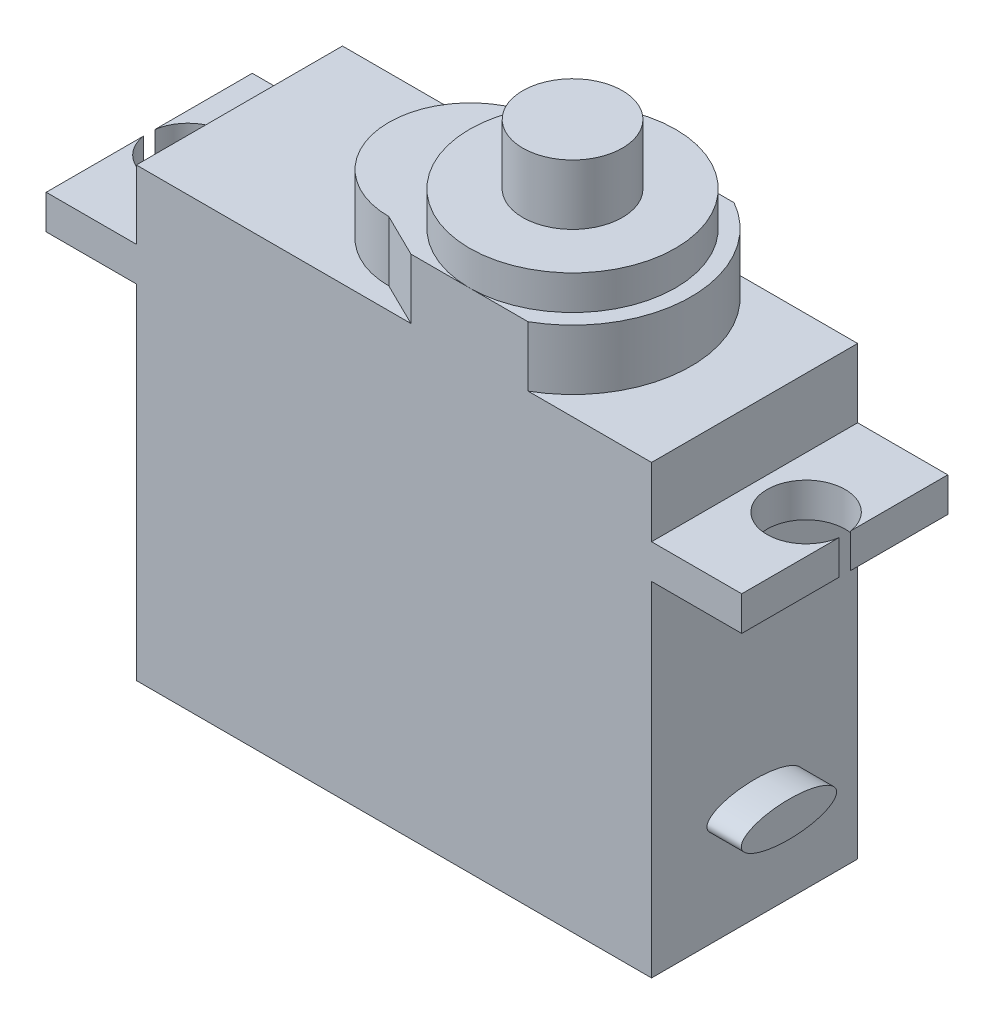
from build123d import *

# Parameters (mm, degrees)
BOSS_EXTRUDE1_DEPTH = 12
SKETCH2_RX          = 2.776601092
SKETCH2_RY          = 1.017784095
BOSS_EXTRUDE2_DEPTH = 2
SKETCH3_R           = 2.275
CUT_EXTRUDE3_DEPTH  = 2
SKETCH5_R           = 2.9
BOSS_EXTRUDE3_DEPTH = 3.5
CUT_EXTRUDE4_DEPTH  = 5.5
CUT_EXTRUDE5_DEPTH  = 2
CUT_EXTRUDE6_DEPTH  = 3.5


with BuildPart() as part:
    # Sketch1 → Boss-Extrude1 (new body)
    with BuildSketch(Plane.XY):
        Polygon((0, 22), (0, 26), (8.7, 26), (8.7, 31.5), (26.3, 31.5), (26.3, 26), (30, 26), (30, 22), (35.25, 22), (35.25, 20), (30, 20), (30, 0), (0, 0), (0, 20), (-5.25, 20), (-5.25, 22), align=None)
    extrude(amount=BOSS_EXTRUDE1_DEPTH)

    # Sketch2 → Boss-Extrude2 (add)
    with BuildSketch(Plane(origin=(30, 0, 0), x_dir=(0, 0, -1), z_dir=(1, 0, 0))):
        with Locations((-6, 6)):
            Ellipse(SKETCH2_RX, SKETCH2_RY)
    extrude(amount=BOSS_EXTRUDE2_DEPTH)

    # Sketch3 → Cut-Extrude3 (cut)
    with BuildSketch(Plane(origin=(0, 22, 0), x_dir=(1, 0, 0), z_dir=(0, 1, 0))):
        with Locations((-3, -6)):
            Circle(SKETCH3_R)
        with Locations((33, -6)):
            Circle(SKETCH3_R)
    extrude(amount=-CUT_EXTRUDE3_DEPTH, mode=Mode.SUBTRACT)

    # Sketch5 → Boss-Extrude3 (add)
    with BuildSketch(Plane(origin=(0, 31.5, 0), x_dir=(1, 0, 0), z_dir=(0, 1, 0))):
        with Locations((19.4, -6)):
            Circle(SKETCH5_R)
    extrude(amount=BOSS_EXTRUDE3_DEPTH)

    # Sketch5_3 → Cut-Extrude4 (cut)
    with BuildSketch(Plane(origin=(0, 31.5, 0), x_dir=(1, 0, 0), z_dir=(0, 1, 0))):
        with BuildLine():
            Line((26.3, 0), (22.807345007, 0))
            ThreePointArc((22.807345007, 0), (25.363249137, -2.528738021), (26.3, -6))
            Line((26.3, -6), (26.3, 0))
        make_face()
        with BuildLine():
            Line((26.3, -12), (26.3, -6))
            ThreePointArc((26.3, -6), (25.363249137, -9.471261979), (22.807345007, -12))
            Line((22.807345007, -12), (26.3, -12))
        make_face()
    extrude(amount=-CUT_EXTRUDE4_DEPTH, mode=Mode.SUBTRACT)

    # Sketch7 → Cut-Extrude5 (cut)
    with BuildSketch(Plane(origin=(0, 31.5, 0), x_dir=(1, 0, 0), z_dir=(0, 1, 0))):
        with BuildLine():
            ThreePointArc((22.807345007, -12), (26.3, -6), (22.807345007, 0))
            Line((22.807345007, 0), (19.4, 0))
            ThreePointArc((19.4, 0), (23.642640687, -1.757359313), (25.4, -6))
            ThreePointArc((25.4, -6), (23.642640687, -10.242640687), (19.4, -12))
            Line((19.4, -12), (22.807345007, -12))
        make_face()
        with BuildLine():
            ThreePointArc((19.4, -12), (13.4, -6), (19.4, 0))
            Line((19.4, 0), (8.7, 0))
            Line((8.7, 0), (8.7, -12))
            Line((8.7, -12), (19.4, -12))
        make_face()
    extrude(amount=-CUT_EXTRUDE5_DEPTH, mode=Mode.SUBTRACT)

    # Sketch8 → Cut-Extrude6 (cut)
    with BuildSketch(Plane(origin=(0, 29.5, 0), x_dir=(1, 0, 0), z_dir=(0, 1, 0))):
        with BuildLine():
            Line((8.7, 0), (8.7, -6))
            ThreePointArc((8.7, -6), (10.091242789, -2.641242789), (13.45, -1.25))
            Line((13.45, -1.25), (15.992654993, 0))
            Line((15.992654993, 0), (8.7, 0))
        make_face()
        with BuildLine():
            Line((15.988961876, -12), (13.45, -10.75))
            ThreePointArc((13.45, -10.75), (10.091242789, -9.358757211), (8.7, -6))
            Line((8.7, -6), (8.7, -12))
            Line((8.7, -12), (15.988961876, -12))
        make_face()
    extrude(amount=-CUT_EXTRUDE6_DEPTH, mode=Mode.SUBTRACT)


solid = part.part
